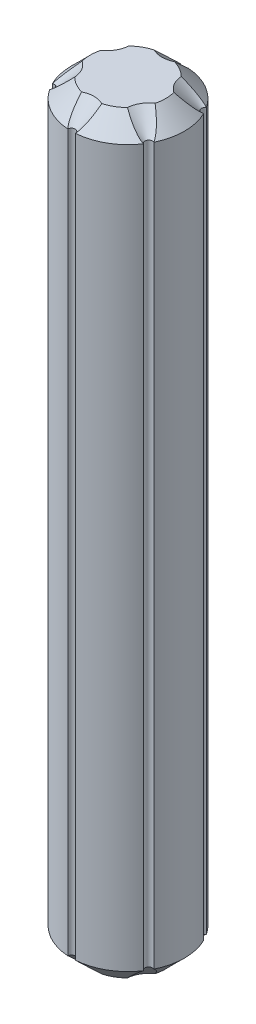
from build123d import *

# Parameters (mm, degrees)
SKETCH1_R           = 3
BOSS_EXTRUDE1_DEPTH = 40
CUT_EXTRUDE1_START  = -41
SKETCH2_R           = 0.2
CUT_EXTRUDE1_DEPTH  = 42
CIRPATTERN1_COUNT   = 6
CHAMFER1_SIZE       = 1


with BuildPart() as part:
    # Sketch1 → Boss-Extrude1 (new body)
    with BuildSketch(Plane(origin=(0, 0, 0), x_dir=(1, 0, 0), z_dir=(0, 1, 0))):
        Circle(SKETCH1_R)
    extrude(amount=BOSS_EXTRUDE1_DEPTH)

    # Sketch2 → Cut-Extrude1 (cut)
    with BuildSketch(Plane(origin=(0, 40, 0), x_dir=(1, 0, 0), z_dir=(0, 1, 0)).offset(CUT_EXTRUDE1_START)):
        with Locations((0, 3)):
            Circle(SKETCH2_R)
    cut_extrude1 = extrude(amount=CUT_EXTRUDE1_DEPTH, mode=Mode.SUBTRACT)

    # CirPattern1: Cut-Extrude1 ×6 about axis
    cirpattern1_axis = Axis((0, 0, 0), (0, 1, 0))
    for i in range(1, CIRPATTERN1_COUNT):
        add(cut_extrude1.rotate(cirpattern1_axis, i * 360 / CIRPATTERN1_COUNT), mode=Mode.SUBTRACT)

    # Chamfer1
    chamfer1_edges = [part.edges().sort_by_distance(p)[0] for p in [
        (-3, 0, 0),
        (-1.5, 0, 2.598076211),
        (1.5, 0, 2.598076211),
        (3, 0, 0),
        (1.5, 0, -2.598076211),
        (-2.424871131, 0, -1.4),
        (-2.424871131, 0, 1.4),
        (0, 0, 2.8),
        (2.424871131, 0, 1.4),
        (2.424871131, 0, -1.4),
        (-3, 40, 0),
        (-1.5, 40, 2.598076211),
        (1.5, 40, 2.598076211),
        (3, 40, 0),
        (1.5, 40, -2.598076211),
        (2.424871131, 40, -1.4),
        (2.424871131, 40, 1.4),
        (0, 40, 2.8),
        (-2.424871131, 40, 1.4),
        (-2.424871131, 40, -1.4),
        (-1.5, 0, -2.598076211),
        (0, 0, -2.8),
        (-1.5, 40, -2.598076211),
        (0, 40, -2.8),
    ]]
    chamfer(chamfer1_edges, length=CHAMFER1_SIZE)


solid = part.part
